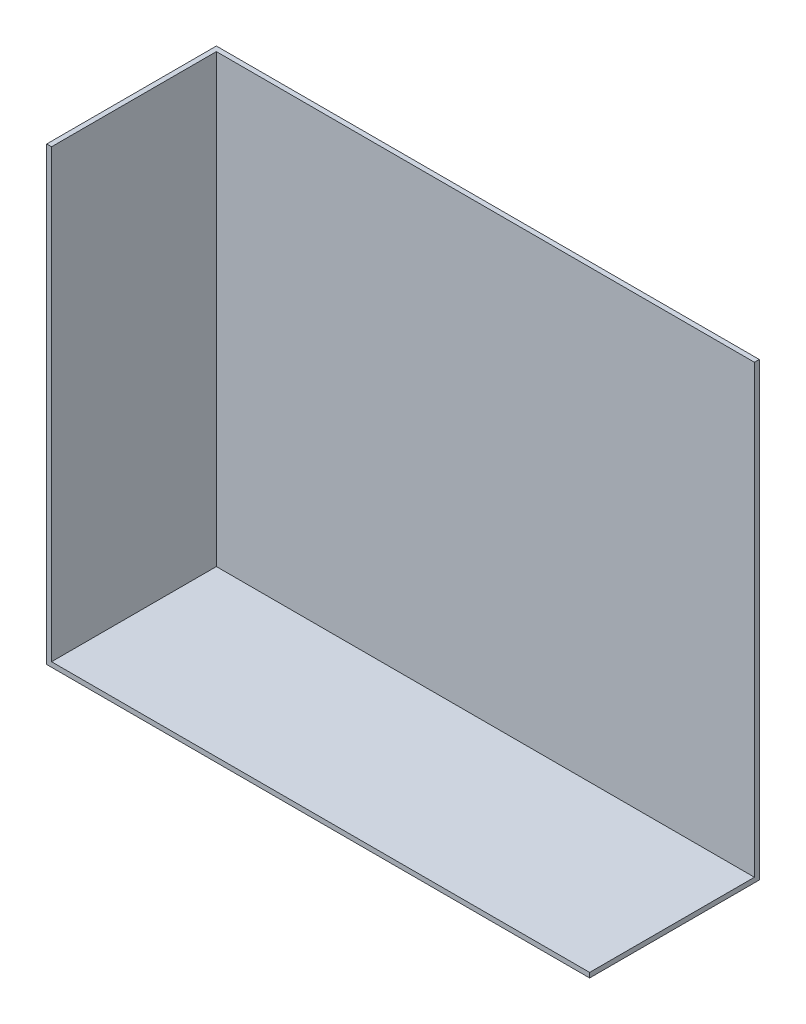
from build123d import *

# Parameters (mm, degrees)
SKETCH1_W           = 2844.8
SKETCH1_H           = 889
BOSS_EXTRUDE1_DEPTH = 2362.2
SHELL1_T            = -25.4


with BuildPart() as part:
    # Sketch1 → Boss-Extrude1 (new body)
    with BuildSketch(Plane(origin=(0, 0, 0), x_dir=(1, 0, 0), z_dir=(0, 1, 0))):
        Rectangle(SKETCH1_W, SKETCH1_H)
    extrude(amount=BOSS_EXTRUDE1_DEPTH)

    # Shell1
    shell1_openings = [part.faces().sort_by_distance(p)[0] for p in [
        (0, 2362.2, 0),
        (1422.4, 1181.1, 0),
        (0, 1181.1, 444.5),
    ]]
    offset(amount=SHELL1_T, openings=shell1_openings, kind=Kind.INTERSECTION)


solid = part.part
